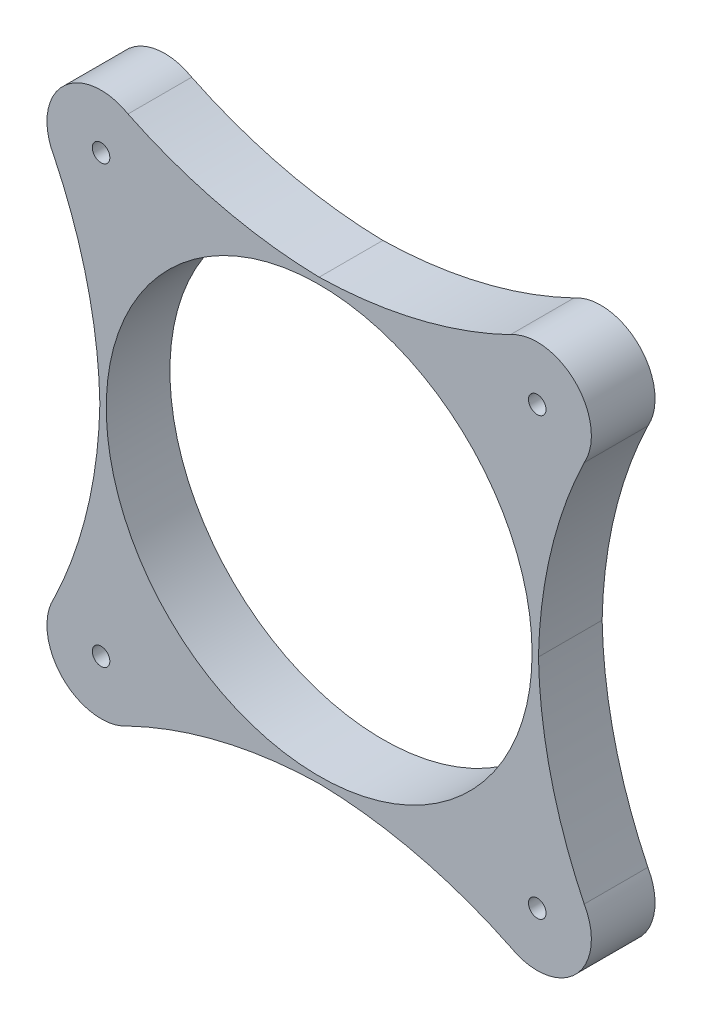
from build123d import *

# Parameters (mm, degrees)
SKETCH1_R                               = 84.93125
BOSS_EXTRUDE1_DEPTH                     = 25.4
CBORE_FOR_M6_HEX_HEAD_BOLT1_D           = 7
CBORE_FOR_M6_HEX_HEAD_BOLT1_CBORE_D     = 14.547
CBORE_FOR_M6_HEX_HEAD_BOLT1_CBORE_DEPTH = 4


with BuildPart() as part:
    # Sketch1 → Boss-Extrude1 (new body)
    with BuildSketch(Plane.XY):
        with BuildLine():
            ThreePointArc((-76.246005737, 105.719498865), (-39.105377809, 92.490752346), (0, 87.47125))
            ThreePointArc((0, 87.47125), (39.105377809, 92.490752346), (76.246005737, 105.719498865))
            ThreePointArc((76.246005737, 105.719498865), (102.262666579, 102.262666579), (105.719498865, 76.246005737))
            ThreePointArc((105.719498865, 76.246005737), (92.490752346, 39.105377809), (87.47125, 0))
            ThreePointArc((87.47125, 0), (92.490752346, -39.105377809), (105.719498865, -76.246005737))
            ThreePointArc((105.719498865, -76.246005737), (102.262666579, -102.262666579), (76.246005737, -105.719498865))
            ThreePointArc((76.246005737, -105.719498865), (39.105377809, -92.490752346), (0, -87.47125))
            ThreePointArc((0, -87.47125), (-39.105377809, -92.490752346), (-76.246005737, -105.719498865))
            ThreePointArc((-76.246005737, -105.719498865), (-102.262666579, -102.262666579), (-105.719498865, -76.246005737))
            ThreePointArc((-105.719498865, -76.246005737), (-92.490752346, -39.105377809), (-87.47125, 0))
            ThreePointArc((-87.47125, 0), (-92.490752346, 39.105377809), (-105.719498865, 76.246005737))
            ThreePointArc((-105.719498865, 76.246005737), (-102.262666579, 102.262666579), (-76.246005737, 105.719498865))
        make_face()
        Circle(SKETCH1_R, mode=Mode.SUBTRACT)
    extrude(amount=BOSS_EXTRUDE1_DEPTH)

    # CBORE for M6 Hex Head Bolt1 (through all)
    with Locations(Plane(origin=(0, 0, 0), x_dir=(-1, 0, 0), z_dir=(0, 0, -1))):
        with Locations((-86.996231173, 86.996231173), (86.996231173, 86.996231173), (86.996231173, -86.996231173), (-86.996231173, -86.996231173)):
            CounterBoreHole(CBORE_FOR_M6_HEX_HEAD_BOLT1_D / 2, CBORE_FOR_M6_HEX_HEAD_BOLT1_CBORE_D / 2, CBORE_FOR_M6_HEX_HEAD_BOLT1_CBORE_DEPTH)


solid = part.part
